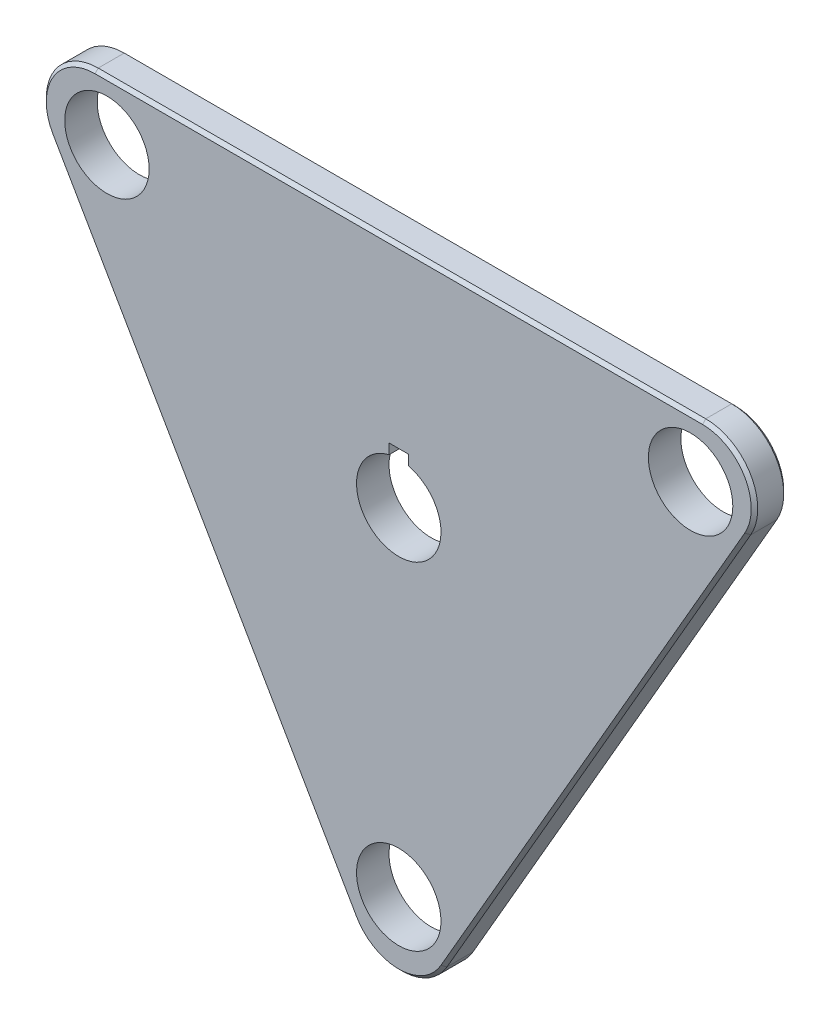
from build123d import *

# Parameters (mm, degrees)
SKETCH1_R           = 6.5
BOSS_EXTRUDE1_DEPTH = 5
CHAMFER1_SIZE       = 0.5
CHAMFER2_SIZE       = 0.5
SKETCH2_R           = 6.5
CUT_EXTRUDE1_DEPTH  = 6
CUT_EXTRUDE2_DEPTH  = 10


with BuildPart() as part:
    # Sketch1 → Boss-Extrude1 (new body)
    with BuildSketch(Plane.XY):
        with BuildLine():
            Line((6.92820323, -58), (53.693575035, 23))
            ThreePointArc((53.693575035, 23), (53.693575035, 31), (46.765371804, 35))
            Line((46.765371804, 35), (-46.765371804, 35))
            ThreePointArc((-46.765371804, 35), (-53.693575035, 31), (-53.693575035, 23))
            Line((-53.693575035, 23), (-6.92820323, -58))
            ThreePointArc((-6.92820323, -58), (0, -62), (6.92820323, -58))
        make_face()
        with Locations((-44.929397948, 25.94)):
            Circle(SKETCH1_R, mode=Mode.SUBTRACT)
        with Locations((44.929397948, 25.94)):
            Circle(SKETCH1_R, mode=Mode.SUBTRACT)
        with Locations((0, -51.88)):
            Circle(SKETCH1_R, mode=Mode.SUBTRACT)
    extrude(amount=-BOSS_EXTRUDE1_DEPTH)

    # Chamfer1
    chamfer1_edges = [part.edges().sort_by_distance(p)[0] for p in [
        (0, 35, 0),
        (53.693575035, 31, 0),
        (30.310889132, -17.5, 0),
        (0, -62, 0),
        (-30.310889132, -17.5, 0),
        (-53.693575035, 31, 0),
    ]]
    chamfer(chamfer1_edges, length=CHAMFER1_SIZE)

    # Chamfer2
    chamfer2_edges = [part.edges().sort_by_distance(p)[0] for p in [
        (0, -62, -5),
        (30.310889132, -17.5, -5),
        (53.693575035, 31, -5),
        (0, 35, -5),
        (-53.693575035, 31, -5),
        (-30.310889132, -17.5, -5),
    ]]
    chamfer(chamfer2_edges, length=CHAMFER2_SIZE)

    # Sketch2 → Cut-Extrude1 (cut, through all)
    with BuildSketch(Plane.XY):
        Circle(SKETCH2_R)
    extrude(amount=-CUT_EXTRUDE1_DEPTH, mode=Mode.SUBTRACT)

    # Sketch3 → Cut-Extrude2 (cut)
    with BuildSketch(Plane.XY):
        Polygon((-1.5, 6.5), (-1.5, 7.9), (1.5, 7.9), (1.5, 6.5), (1.5, 6.224814872), (-1.5, 6.224814872), align=None)
    extrude(amount=-CUT_EXTRUDE2_DEPTH, mode=Mode.SUBTRACT)


solid = part.part
